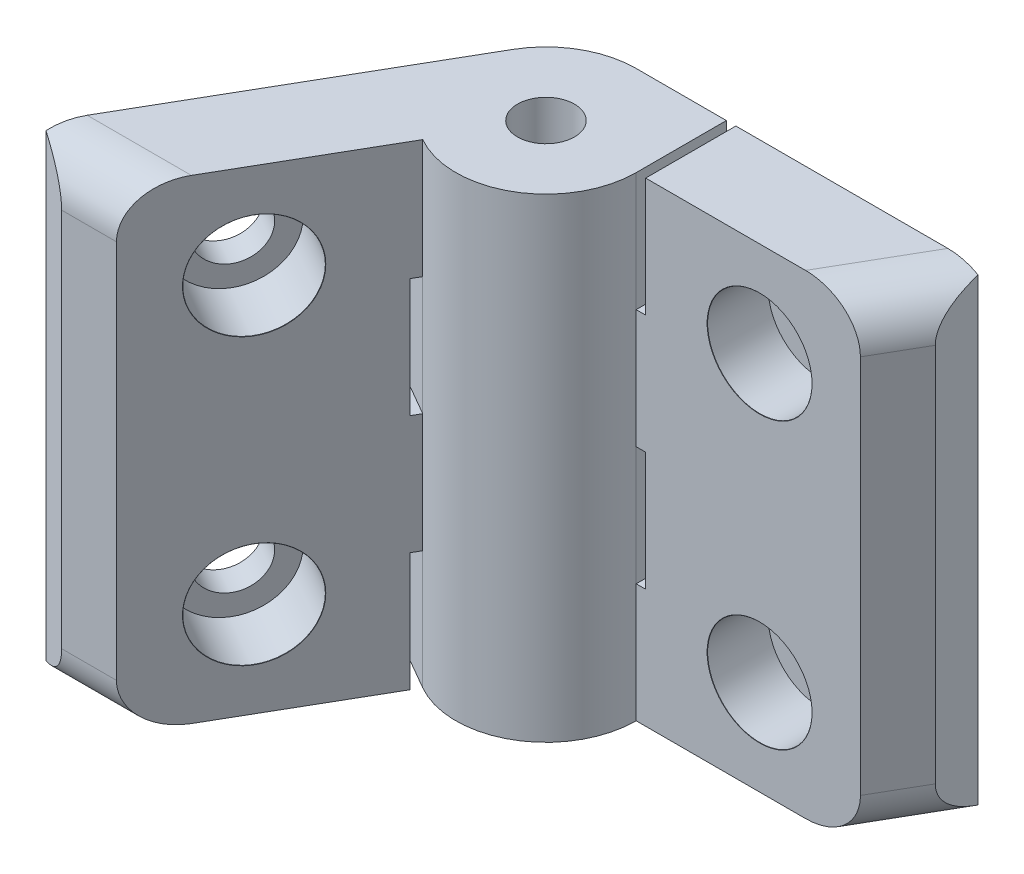
from build123d import *

# Parameters (mm, degrees)
SKETCH_9_R                  = 3
EXTRUDE_4_DEPTH             = 25
EXTRUDE_4_DEPTH_BACK        = 25
EXTRUDE_5_REACH             = 27
SKETCH_10_R                 = 3
EXTRUDE_5_DIRECTION_2_REACH = 27
HOLE_WIZARD_M61_AT_2_COUNT  = 2
HOLE_WIZARD_M61_AT_2_PITCH  = 30
HOLE_WIZARD_M62_AT_2_COUNT  = 2
HOLE_WIZARD_M62_AT_2_PITCH  = 30
CHAMFER_1_SIZE              = 5
CHAMFER_1_SIZE2             = 2.886751346
CHAMFER_1_PART_2_SIZE       = 5
CHAMFER_1_PART_2_SIZE2      = 2.886751346
SKETCH_15_W                 = 1
SKETCH_15_H                 = 12.5
CUT_EXTRUDE_1_DEPTH         = 10.5
SKETCH_16_W                 = 1
SKETCH_16_H                 = 12.5
CUT_EXTRUDE_2_DEPTH         = 28.463457268
FILLET_2_R                  = 5


with BuildPart() as part:
    # Sketch 9 → Extrude 4 (new body, two sides)
    with BuildSketch(Plane(origin=(0, 0, 0), x_dir=(1, 0, 0), z_dir=(0, 1, 0))) as extrude_4_sk:
        with BuildLine():
            Line((0, 9.5), (36, 9.5))
            Line((36, 9.5), (36, 0))
            Line((36, 0), (9.5, 0))
            ThreePointArc((9.5, 0), (-6.717514421, -6.717514421), (0, 9.5))
        make_face()
        with Locations(Location((0, 0, 0), (0, 0, 270))):  # turned: the seam where the file's is
            Circle(SKETCH_9_R, mode=Mode.SUBTRACT)
    extrude(amount=EXTRUDE_4_DEPTH)
    extrude(extrude_4_sk.sketch, amount=-EXTRUDE_4_DEPTH_BACK)

    # Extrude 5: up to this face of the body (flat: up to its plane)
    extrude_5_end = Plane(part.part.faces().sort_by_distance((11.152200141, 25, -2.543273154))[0])
    # Sketch 10 → Extrude 5 (add, up to the picked face)
    with BuildSketch(Plane(origin=(0, 0, 0), x_dir=(1, 0, 0), z_dir=(0, 1, 0)), mode=Mode.PRIVATE) as extrude_5_sk1:
        with BuildLine():
            Line((-8.227241336, 4.75), (-26.227241336, -26.426914536))
            Line((-26.227241336, -26.426914536), (-18, -31.176914536))
            Line((-18, -31.176914536), (-4.75, -8.227241336))
            ThreePointArc((-4.75, -8.227241336), (9.17629535, 2.458780928), (-8.227241336, 4.75))
        make_face()
        with Locations(Location((0, 0, 0), (0, 0, 270))):  # turned: the seam where the file's is
            Circle(SKETCH_10_R, mode=Mode.SUBTRACT)
    extrude_5_tool1 = split(extrude(extrude_5_sk1.sketch, amount=EXTRUDE_5_REACH, mode=Mode.PRIVATE), bisect_by=extrude_5_end, keep=Keep.BOTH, mode=Mode.PRIVATE)
    add(extrude_5_tool1.solids().sort_by(Axis((-7.778639, 0, 8.386452), (0, 1, 0)))[0])

    # Extrude 5 direction 2: up to this face of the body (flat: up to its plane)
    extrude_5_direction_2_end = Plane(part.part.faces().sort_by_distance((11.152200141, -25, -2.543273154))[0])
    # Sketch 10 → Extrude 5 direction 2 (add, up to the picked face)
    with BuildSketch(Plane(origin=(0, 0, 0), x_dir=(1, 0, 0), z_dir=(0, 1, 0)), mode=Mode.PRIVATE) as extrude_5_direction_2_sk1:
        with BuildLine():
            Line((-8.227241336, 4.75), (-26.227241336, -26.426914536))
            Line((-26.227241336, -26.426914536), (-18, -31.176914536))
            Line((-18, -31.176914536), (-4.75, -8.227241336))
            ThreePointArc((-4.75, -8.227241336), (9.17629535, 2.458780928), (-8.227241336, 4.75))
        make_face()
        with Locations(Location((0, 0, 0), (0, 0, 270))):  # turned: the seam where the file's is
            Circle(SKETCH_10_R, mode=Mode.SUBTRACT)
    extrude_5_direction_2_tool1 = split(extrude(extrude_5_direction_2_sk1.sketch, amount=-EXTRUDE_5_DIRECTION_2_REACH, mode=Mode.PRIVATE), bisect_by=extrude_5_direction_2_end, keep=Keep.BOTH, mode=Mode.PRIVATE)
    add(extrude_5_direction_2_tool1.solids().sort_by(Axis((-7.778639, 0, 8.386452), (0, -1, 0)))[0])

    # Sketch 12 → Hole Wizard M61 (revolve, cut)
    with BuildSketch(Plane(origin=(22.5, 15, 0), x_dir=(0, -1, 0), z_dir=(1, 0, 0))):
        Polygon((0, 0), (0, 9.5), (3.3, 9.5), (3.3, 6.4), (5.5, 6.4), (5.5, 0.025), (5.525, 0), align=None)
    hole_wizard_m61 = revolve(axis=Axis((22.5, 15, 6.35), (0, 0, -1)), mode=Mode.SUBTRACT)

    # Hole Wizard M61 at 2: Hole Wizard M61 ×2
    with Locations(*[(0, -i * HOLE_WIZARD_M61_AT_2_PITCH, 0) for i in range(1, HOLE_WIZARD_M61_AT_2_COUNT)]):
        add(hole_wizard_m61, mode=Mode.SUBTRACT)

    # Sketch 14 → Hole Wizard M62 (revolve, cut)
    with BuildSketch(Plane(origin=(-11.25, 15, 19.485571585), x_dir=(0.5, 0, -0.866025404), z_dir=(0, 1, 0))):
        Polygon((0, 0), (0, 27.463457268), (3.3, 27.463457268), (3.3, 6.4), (5.5, 6.4), (5.5, 0.025), (5.525, 0), align=None)
    hole_wizard_m62 = revolve(axis=Axis((-5.750738686, 15, 22.660571585), (-0.866025404, 0, -0.5)), mode=Mode.SUBTRACT)

    # Hole Wizard M62 at 2: Hole Wizard M62 ×2
    with Locations(*[(0, -i * HOLE_WIZARD_M62_AT_2_PITCH, 0) for i in range(1, HOLE_WIZARD_M62_AT_2_COUNT)]):
        add(hole_wizard_m62, mode=Mode.SUBTRACT)

    # Chamfer 1
    chamfer_1_edges = [part.edges().sort_by_distance(p)[0] for p in [
        (-18, 0, 31.176914536),
    ]]
    chamfer_1_side = [part.faces().sort_by_distance(p)[0] for p in [
        (-22.113620668, 0, 28.801914536),
    ]]
    chamfer(chamfer_1_edges, length=CHAMFER_1_SIZE, length2=CHAMFER_1_SIZE2, reference=chamfer_1_side[0])

    # Chamfer 1 part 2
    chamfer_1_part_2_edges = [part.edges().sort_by_distance(p)[0] for p in [
        (36, 0, 0),
    ]]
    chamfer_1_part_2_side = [part.faces().sort_by_distance(p)[0] for p in [
        (36, 0, -4.75),
    ]]
    chamfer(chamfer_1_part_2_edges, length=CHAMFER_1_PART_2_SIZE, length2=CHAMFER_1_PART_2_SIZE2, reference=chamfer_1_part_2_side[0])

    # Sketch 15 → Cut-Extrude 1 (cut, through all)
    with BuildSketch(Plane.XY):
        with Locations((10, 18.75)):
            Rectangle(SKETCH_15_W, SKETCH_15_H)
        with Locations((10, -6.25)):
            Rectangle(SKETCH_15_W, SKETCH_15_H)
    extrude(amount=-CUT_EXTRUDE_1_DEPTH, mode=Mode.SUBTRACT)

    # Sketch 16 → Cut-Extrude 2 (cut, through all)
    with BuildSketch(Plane(origin=(0, 0, 0), x_dir=(0.5, 0, -0.866025404), z_dir=(0.866025404, 0, 0.5))):
        with Locations((-10, -18.75)):
            Rectangle(SKETCH_16_W, SKETCH_16_H)
        with Locations((-10, 6.25)):
            Rectangle(SKETCH_16_W, SKETCH_16_H)
    extrude(amount=-CUT_EXTRUDE_2_DEPTH, mode=Mode.SUBTRACT)

    # Fillet 2
    fillet_2_edges = [part.edges().sort_by_distance(p)[0] for p in [
        (34.556624327, 25, -2.5),
        (34.556624327, -25, -2.5),
        (-19.443375673, 25, 28.676914536),
        (-19.443375673, -25, 28.676914536),
    ]]
    fillet(fillet_2_edges, radius=FILLET_2_R)


solid = part.part
